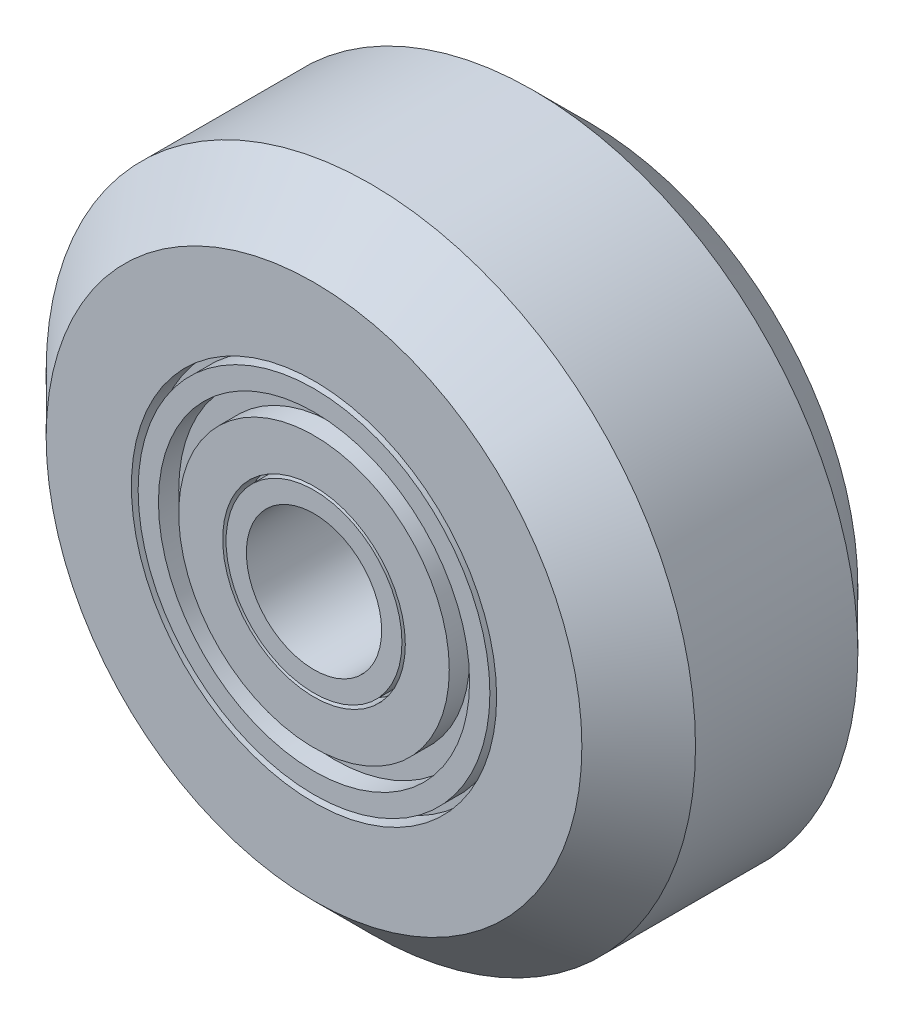
from build123d import *

# Parameters (mm, degrees)
SKETCH1_R           = 12
BOSS_EXTRUDE1_DEPTH = 3
SKETCH3_R           = 12
BOSS_EXTRUDE2_DEPTH = 2.1
BOSS_EXTRUDE2_TAPER = 45
SKETCH4_R           = 12
BOSS_EXTRUDE3_DEPTH = 2.1
BOSS_EXTRUDE3_TAPER = 45
SKETCH5_R           = 2.5
CUT_EXTRUDE1_DEPTH  = 20.800000173
SKETCH6_R           = 6.75
SKETCH6_R_2         = 6.5
SKETCH6_R_3         = 5.75
SKETCH6_R_4         = 5
SKETCH6_R_5         = 3.375
SKETCH6_R_6         = 3.25
CUT_EXTRUDE2_DEPTH  = 0.75


with BuildPart() as part:
    # Sketch1 → Boss-Extrude1 (new, symmetric)
    with BuildSketch(Plane.XY):
        Circle(SKETCH1_R)
    extrude(amount=BOSS_EXTRUDE1_DEPTH, both=True)

    # Sketch3 → Boss-Extrude2 (add)
    with BuildSketch(Plane.XY.offset(3)):
        Circle(SKETCH3_R)
    extrude(amount=BOSS_EXTRUDE2_DEPTH, taper=BOSS_EXTRUDE2_TAPER)

    # Sketch4 → Boss-Extrude3 (add)
    with BuildSketch(Plane(origin=(0, 0, -3), x_dir=(-1, 0, 0), z_dir=(0, 0, -1))):
        Circle(SKETCH4_R)
    extrude(amount=BOSS_EXTRUDE3_DEPTH, taper=BOSS_EXTRUDE3_TAPER)

    # Sketch5 → Cut-Extrude1 (cut, through all)
    with BuildSketch(Plane.XY.offset(5.1)):
        Circle(SKETCH5_R)
    extrude(amount=-CUT_EXTRUDE1_DEPTH, mode=Mode.SUBTRACT)

    # Sketch6 → Cut-Extrude2 (cut)
    with BuildSketch(Plane.XY.offset(5.1)):
        Circle(SKETCH6_R)
        Circle(SKETCH6_R_2, mode=Mode.SUBTRACT)
        Circle(SKETCH6_R_3)
        Circle(SKETCH6_R_4, mode=Mode.SUBTRACT)
        Circle(SKETCH6_R_5)
        Circle(SKETCH6_R_6, mode=Mode.SUBTRACT)
    cut_extrude2 = extrude(amount=-CUT_EXTRUDE2_DEPTH, mode=Mode.SUBTRACT)

    # Mirror1: Cut-Extrude2 across plane
    add(cut_extrude2.mirror(Plane.XY), mode=Mode.SUBTRACT)


solid = part.part
